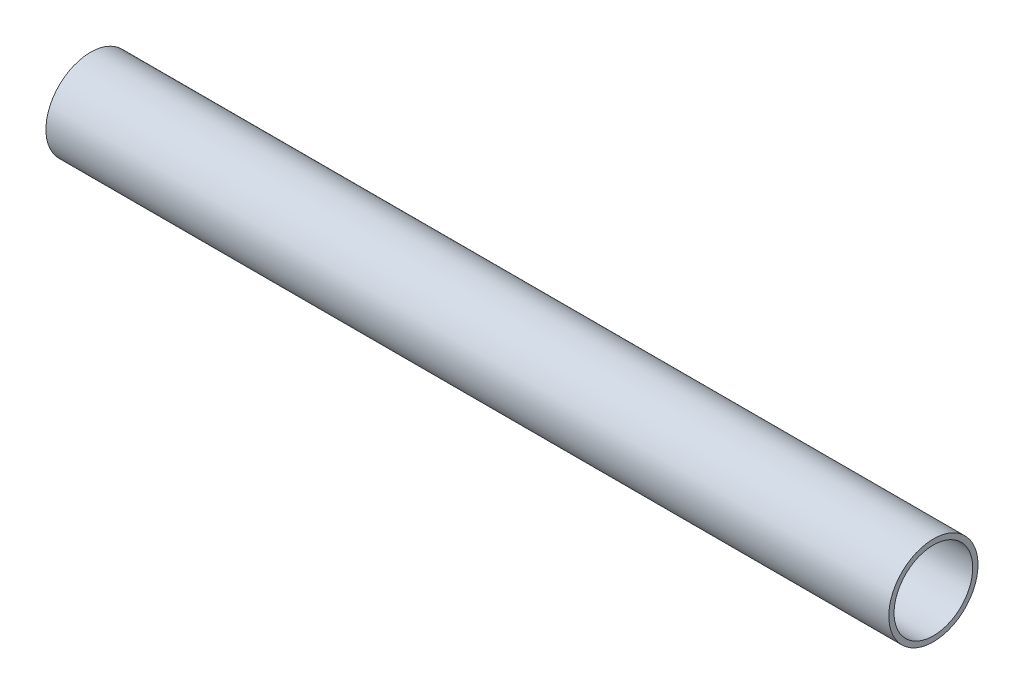
from build123d import *

# Parameters (mm, degrees)
ESQUISSE1_R        = 1.5875
ESQUISSE1_R_2      = 1.4
BOSS_EXTRU_1_DEPTH = 30


with BuildPart() as part:
    # Esquisse1 → Boss.-Extru.1 (new body)
    with BuildSketch(Plane(origin=(0, 0, 0), x_dir=(0, 0, -1), z_dir=(1, 0, 0))):
        Circle(ESQUISSE1_R)
        Circle(ESQUISSE1_R_2, mode=Mode.SUBTRACT)
    extrude(amount=BOSS_EXTRU_1_DEPTH)


solid = part.part
